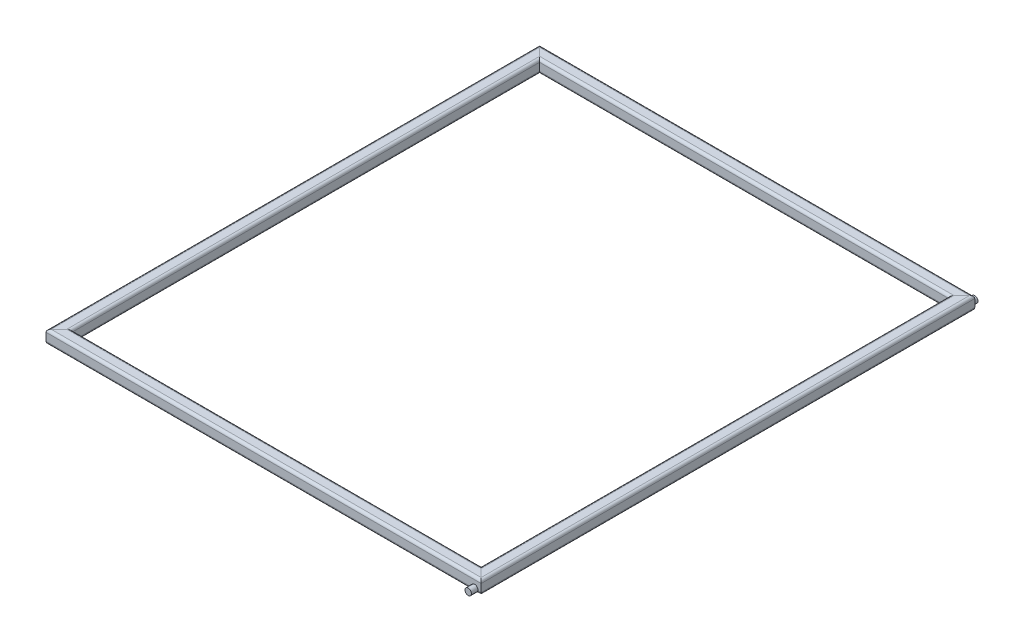
from build123d import *

# Parameters (mm, degrees)
SQUARE_TUBE_CONFIGURED_20_X_20_X_2_1_DEPTH      = 755.142135624
SQUARE_TUBE_CONFIGURED_20_X_20_X_2_1_DEPTH_BACK = 15.142135624
SQUARE_TUBE_CONFIGURED_20_X_20_X_2_1_2_DEPTH    = 680.284271247
SQUARE_TUBE_CONFIGURED_20_X_20_X_2_1_3_DEPTH    = 770.284271247
SQUARE_TUBE_CONFIGURED_20_X_20_X_2_1_4_DEPTH    = 680.284271247
SKETCH13_R                                      = 5
BOSS_EXTRUDE1_DEPTH                             = 10
BOSS_EXTRUDE1_DIRECTION_2_REACH                 = 832.617


with BuildPart() as part:
    # Sketch12 → Square tube - configured 20 X 20 X 2(1) (new, two sides)
    with BuildSketch(Plane(origin=(-325, 0, 370), x_dir=(-1, 0, 0), z_dir=(0, 0, -1))) as square_tube_configured_20_x_20_x_2_1_sk:
        with BuildLine():
            Line((-6, -10), (6, -10))
            ThreePointArc((6, -10), (8.828427125, -8.828427125), (10, -6))
            Line((10, -6), (10, 6))
            ThreePointArc((10, 6), (8.828427125, 8.828427125), (6, 10))
            Line((6, 10), (-6, 10))
            ThreePointArc((-6, 10), (-8.828427125, 8.828427125), (-10, 6))
            Line((-10, 6), (-10, -6))
            ThreePointArc((-10, -6), (-8.828427125, -8.828427125), (-6, -10))
        make_face()
        with BuildLine():
            Line((-6, -8), (6, -8))
            ThreePointArc((6, -8), (7.414213562, -7.414213562), (8, -6))
            Line((8, -6), (8, 6))
            ThreePointArc((8, 6), (7.414213562, 7.414213562), (6, 8))
            Line((6, 8), (-6, 8))
            ThreePointArc((-6, 8), (-7.414213562, 7.414213562), (-8, 6))
            Line((-8, 6), (-8, -6))
            ThreePointArc((-8, -6), (-7.414213562, -7.414213562), (-6, -8))
        make_face(mode=Mode.SUBTRACT)
    extrude(amount=SQUARE_TUBE_CONFIGURED_20_X_20_X_2_1_DEPTH)
    extrude(square_tube_configured_20_x_20_x_2_1_sk.sketch, amount=-SQUARE_TUBE_CONFIGURED_20_X_20_X_2_1_DEPTH_BACK)

    # Square tube - configured 20 X 20 X 2(1) m
    split(bisect_by=Plane(origin=(-325, 0, 370), x_dir=(0, -1, 0), z_dir=(-0.707106781, 0, -0.707106781)), keep=Keep.TOP)

    # Square tube - configured 20 X 20 X 2 2
    split(bisect_by=Plane(origin=(-325, 0, -370), x_dir=(0, -1, 0), z_dir=(-0.707106781, 0, 0.707106781)), keep=Keep.TOP)


with BuildPart() as body_2:
    # Sketch12 on segment 2 (carried to segment 2) → Square tube - configured 20 X 20 X 2_1 2 (new body)
    with BuildSketch(Plane(origin=(-340.142135624, 0, -370), x_dir=(0, 0, -1), z_dir=(1, 0, 0))):
        with BuildLine():
            Line((-6, -10), (6, -10))
            ThreePointArc((6, -10), (8.828427125, -8.828427125), (10, -6))
            Line((10, -6), (10, 6))
            ThreePointArc((10, 6), (8.828427125, 8.828427125), (6, 10))
            Line((6, 10), (-6, 10))
            ThreePointArc((-6, 10), (-8.828427125, 8.828427125), (-10, 6))
            Line((-10, 6), (-10, -6))
            ThreePointArc((-10, -6), (-8.828427125, -8.828427125), (-6, -10))
        make_face()
        with BuildLine():
            Line((-6, -8), (6, -8))
            ThreePointArc((6, -8), (7.414213562, -7.414213562), (8, -6))
            Line((8, -6), (8, 6))
            ThreePointArc((8, 6), (7.414213562, 7.414213562), (6, 8))
            Line((6, 8), (-6, 8))
            ThreePointArc((-6, 8), (-7.414213562, 7.414213562), (-8, 6))
            Line((-8, 6), (-8, -6))
            ThreePointArc((-8, -6), (-7.414213562, -7.414213562), (-6, -8))
        make_face(mode=Mode.SUBTRACT)
    extrude(amount=SQUARE_TUBE_CONFIGURED_20_X_20_X_2_1_2_DEPTH)

    # Square tube - configured 20 X 20 X 2 3
    split(bisect_by=Plane(origin=(325, 0, -370), x_dir=(0, -1, 0), z_dir=(-0.707106781, 0, -0.707106781)), keep=Keep.TOP)

    # Square tube - configured 20 X 20 X 2 4
    split(bisect_by=Plane(origin=(-325, 0, -370), x_dir=(0, 1, 0), z_dir=(0.707106781, 0, -0.707106781)), keep=Keep.TOP)


with BuildPart() as body_3:
    # Sketch12 on segment 3 (carried to segment 3) → Square tube - configured 20 X 20 X 2_1 3 (new body)
    with BuildSketch(Plane(origin=(325, 0, -385.142135624), x_dir=(1, 0, 0), z_dir=(0, 0, 1))):
        with BuildLine():
            Line((-6, -10), (6, -10))
            ThreePointArc((6, -10), (8.828427125, -8.828427125), (10, -6))
            Line((10, -6), (10, 6))
            ThreePointArc((10, 6), (8.828427125, 8.828427125), (6, 10))
            Line((6, 10), (-6, 10))
            ThreePointArc((-6, 10), (-8.828427125, 8.828427125), (-10, 6))
            Line((-10, 6), (-10, -6))
            ThreePointArc((-10, -6), (-8.828427125, -8.828427125), (-6, -10))
        make_face()
        with BuildLine():
            Line((-6, -8), (6, -8))
            ThreePointArc((6, -8), (7.414213562, -7.414213562), (8, -6))
            Line((8, -6), (8, 6))
            ThreePointArc((8, 6), (7.414213562, 7.414213562), (6, 8))
            Line((6, 8), (-6, 8))
            ThreePointArc((-6, 8), (-7.414213562, 7.414213562), (-8, 6))
            Line((-8, 6), (-8, -6))
            ThreePointArc((-8, -6), (-7.414213562, -7.414213562), (-6, -8))
        make_face(mode=Mode.SUBTRACT)
    extrude(amount=SQUARE_TUBE_CONFIGURED_20_X_20_X_2_1_3_DEPTH)

    # Square tube - configured 20 X 20 X 2 5
    split(bisect_by=Plane(origin=(325, 0, 370), x_dir=(0, 1, 0), z_dir=(0.707106781, 0, -0.707106781)), keep=Keep.TOP)

    # Square tube - configured 20 X 20 X 2 6
    split(bisect_by=Plane(origin=(325, 0, -370), x_dir=(0, 1, 0), z_dir=(0.707106781, 0, 0.707106781)), keep=Keep.TOP)


with BuildPart() as body_4:
    # Sketch12 on segment 4 (carried to segment 4) → Square tube - configured 20 X 20 X 2_1 4 (new body)
    with BuildSketch(Plane(origin=(340.142135624, 0, 370), x_dir=(0, 0, 1), z_dir=(-1, 0, 0))):
        with BuildLine():
            Line((-6, -10), (6, -10))
            ThreePointArc((6, -10), (8.828427125, -8.828427125), (10, -6))
            Line((10, -6), (10, 6))
            ThreePointArc((10, 6), (8.828427125, 8.828427125), (6, 10))
            Line((6, 10), (-6, 10))
            ThreePointArc((-6, 10), (-8.828427125, 8.828427125), (-10, 6))
            Line((-10, 6), (-10, -6))
            ThreePointArc((-10, -6), (-8.828427125, -8.828427125), (-6, -10))
        make_face()
        with BuildLine():
            Line((-6, -8), (6, -8))
            ThreePointArc((6, -8), (7.414213562, -7.414213562), (8, -6))
            Line((8, -6), (8, 6))
            ThreePointArc((8, 6), (7.414213562, 7.414213562), (6, 8))
            Line((6, 8), (-6, 8))
            ThreePointArc((-6, 8), (-7.414213562, 7.414213562), (-8, 6))
            Line((-8, 6), (-8, -6))
            ThreePointArc((-8, -6), (-7.414213562, -7.414213562), (-6, -8))
        make_face(mode=Mode.SUBTRACT)
    extrude(amount=SQUARE_TUBE_CONFIGURED_20_X_20_X_2_1_4_DEPTH)

    # Square tube - configured 20 X 20 X 2 7
    split(bisect_by=Plane(origin=(325, 0, 370), x_dir=(0, -1, 0), z_dir=(-0.707106781, 0, 0.707106781)), keep=Keep.TOP)

    # Square tube - configured 20 X 20 X 2 8
    split(bisect_by=Plane(origin=(-325, 0, 370), x_dir=(0, 1, 0), z_dir=(0.707106781, 0, 0.707106781)), keep=Keep.TOP)


with BuildPart() as body_5:
    # Sketch13 → Boss-Extrude1 (new body)
    with BuildSketch(Plane.XY.offset(380)):
        with Locations((325, -5)):
            Circle(SKETCH13_R)
    boss_extrude1 = extrude(amount=BOSS_EXTRUDE1_DEPTH)


    # Sketch13 → Boss-Extrude1 direction 2 (add, up to next)
    with BuildSketch(Plane.XY.offset(380), mode=Mode.PRIVATE) as boss_extrude1_direction_2_sk1:
        with Locations((325, -5)):
            Circle(SKETCH13_R)
    boss_extrude1_direction_2_tool1 = extrude(boss_extrude1_direction_2_sk1.sketch, amount=-BOSS_EXTRUDE1_DIRECTION_2_REACH, mode=Mode.PRIVATE) - body_4.part
    boss_extrude1_direction_2 = boss_extrude1_direction_2_tool1.solids().sort_by_distance((325, -5, 380))[0]
    add(boss_extrude1_direction_2)


with BuildPart() as body_2_1:
    add(body_2.part)

    # Mirror2: Boss-Extrude1, Boss-Extrude1 direction 2 across plane
    add(boss_extrude1.mirror(Plane.XY))
    add(boss_extrude1_direction_2.mirror(Plane.XY))


solid = Compound([part.part, body_3.part, body_4.part, body_5.part, body_2_1.part])
